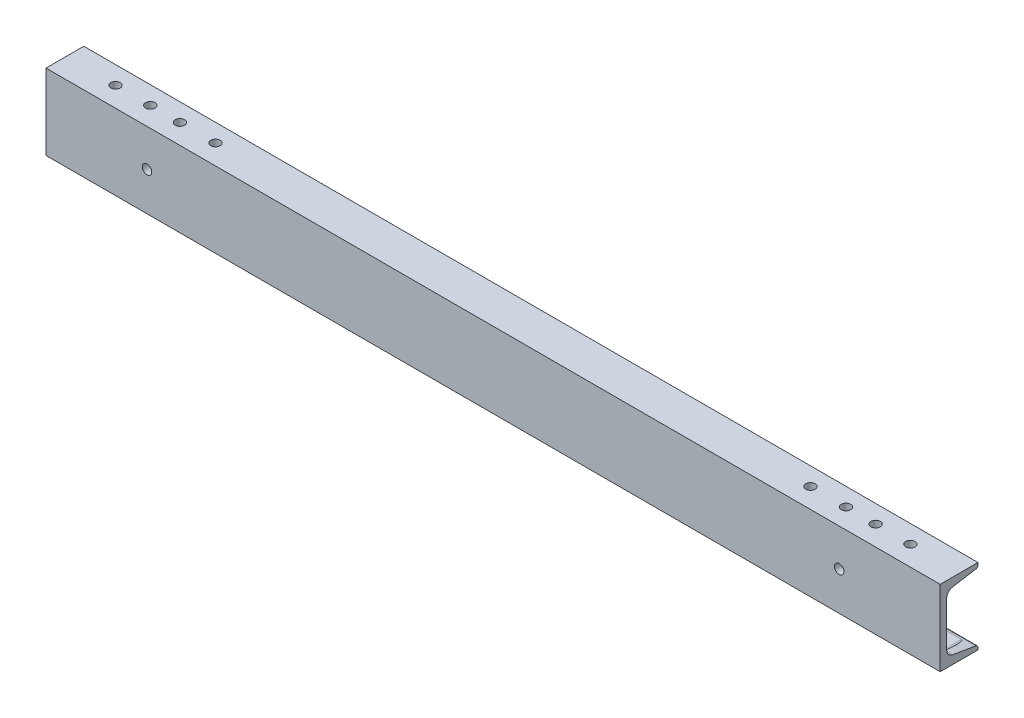
from build123d import *

# Parameters (mm, degrees)
STRUCTURAL_MEMBER1_DEPTH = 900
SKETCH12_R               = 4.7625
CUT_EXTRUDE1_DEPTH       = 454.210052427
CUT_EXTRUDE2_DEPTH       = 40
SKETCH16_R               = 4.7625
CUT_EXTRUDE3_DEPTH       = 454.210052526
SKETCH19_R               = 4.7625
CUT_EXTRUDE4_DEPTH       = 454.210052526


with BuildPart() as part:
    # Sketch11 → Structural Member1 (new body)
    with BuildSketch(Plane(origin=(-450, 0, 0), x_dir=(0, 0, -1), z_dir=(1, 0, 0))):
        with BuildLine():
            Line((0, -38.1), (0, 38.1))
            Line((0, 38.1), (38.0492, 38.1))
            Line((38.0492, 38.1), (38.0492, 35.942335136))
            ThreePointArc((38.0492, 35.942335136), (37.447280466, 34.300554363), (35.926803066, 33.436899509))
            Line((35.926803066, 33.436899509), (12.283671721, 29.496090157))
            ThreePointArc((12.283671721, 29.496090157), (8.178382741, 27.164222052), (6.5532, 22.731413966))
            Line((6.5532, 22.731413966), (6.5532, -22.731413966))
            ThreePointArc((6.5532, -22.731413966), (8.178382741, -27.164222052), (12.283671721, -29.496090157))
            Line((12.283671721, -29.496090157), (35.926803066, -33.436899509))
            ThreePointArc((35.926803066, -33.436899509), (37.447280466, -34.300554363), (38.0492, -35.942335136))
            Line((38.0492, -35.942335136), (38.0492, -38.1))
            Line((38.0492, -38.1), (0, -38.1))
        make_face()
    extrude(amount=STRUCTURAL_MEMBER1_DEPTH)

    # Sketch12 → Cut-Extrude1 (cut, through all)
    with BuildSketch(Plane(origin=(0, 0, 0), x_dir=(1, 0, 0), z_dir=(0, 1, 0))):
        with Locations(Location((-425, 20, 0), (0, 0, 270))):
            Circle(SKETCH12_R)
        with Locations(Location((425, 20, 0), (0, 0, 270))):
            Circle(SKETCH12_R)
    extrude(amount=-CUT_EXTRUDE1_DEPTH, mode=Mode.SUBTRACT)

    # Sketch15 → Cut-Extrude2 (cut)
    with BuildSketch(Plane(origin=(0, 0, -6.5532), x_dir=(-1, 0, 0), z_dir=(0, 0, -1))):
        with BuildLine():
            Line((-412.5, -33.1), (-437.5, -33.1))
            ThreePointArc((-437.5, -33.1), (-442.5, -28.1), (-437.5, -23.1))
            Line((-437.5, -23.1), (-412.5, -23.1))
            ThreePointArc((-412.5, -23.1), (-407.5, -28.1), (-412.5, -33.1))
        make_face()
        with BuildLine():
            Line((412.5, -33.1), (437.5, -33.1))
            ThreePointArc((437.5, -33.1), (442.5, -28.1), (437.5, -23.1))
            Line((437.5, -23.1), (412.5, -23.1))
            ThreePointArc((412.5, -23.1), (407.5, -28.1), (412.5, -33.1))
        make_face()
    extrude(amount=CUT_EXTRUDE2_DEPTH, mode=Mode.SUBTRACT)

    # Sketch16 → Cut-Extrude3 (cut, through all)
    with BuildSketch(Plane(origin=(0, 0, 0), x_dir=(1, 0, 0), z_dir=(0, 1, 0))):
        with Locations(Location((-335.2, 20, 0), (0, 0, 270))):
            Circle(SKETCH16_R)
        with Locations(Location((-299.4, 20, 0), (0, 0, 270))):
            Circle(SKETCH16_R)
        with Locations(Location((299.4, 20, 0), (0, 0, 90))):
            Circle(SKETCH16_R)
        with Locations(Location((335.2, 20, 0), (0, 0, 90))):
            Circle(SKETCH16_R)
        with Locations(Location((-365, 20, 0), (0, 0, 270))):
            Circle(SKETCH16_R)
        with Locations(Location((-400, 20, 0), (0, 0, 270))):
            Circle(SKETCH16_R)
        with Locations(Location((365, 20, 0), (0, 0, 90))):
            Circle(SKETCH16_R)
        with Locations(Location((400, 20, 0), (0, 0, 90))):
            Circle(SKETCH16_R)
    extrude(amount=CUT_EXTRUDE3_DEPTH, mode=Mode.SUBTRACT)

    # Sketch19 → Cut-Extrude4 (cut, through all)
    with BuildSketch(Plane.XY):
        with Locations((-348.3375, 0.6)):
            Circle(SKETCH19_R)
        with Locations((348.3375, 0.6)):
            Circle(SKETCH19_R)
    extrude(amount=-CUT_EXTRUDE4_DEPTH, mode=Mode.SUBTRACT)


solid = part.part
